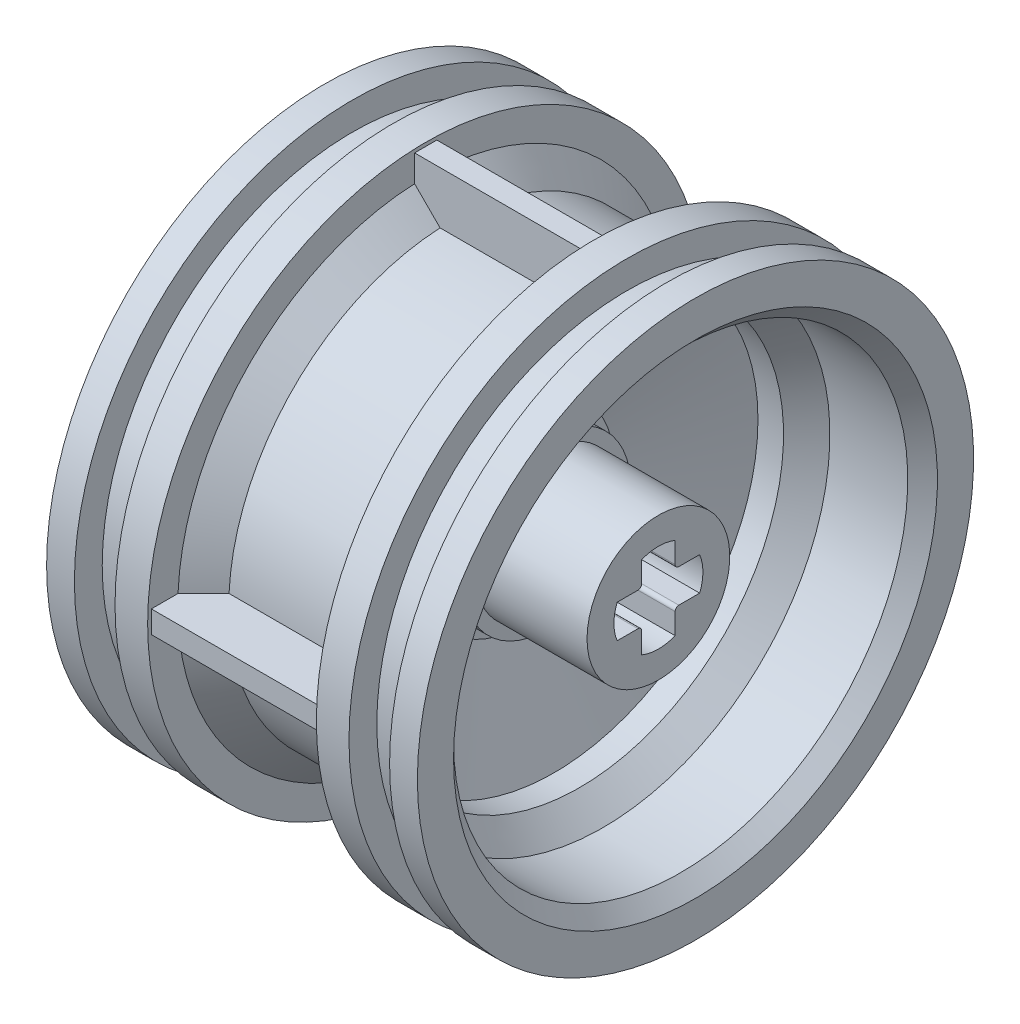
from build123d import *

# Parameters (mm, degrees)
CUT_EXTRUDE2_REACH = 29.821
RIB1_REACH         = 25.452
SKETCH7_WALL_W     = 58.004157598
SKETCH7_WALL_H     = 1.2
CIRPATTERN1_COUNT  = 4
CHAMFER1_SIZE      = 0.8


with BuildPart() as part:
    # Sketch1 → Revolve1 (revolve)
    with BuildSketch(Plane.XY, mode=Mode.PRIVATE) as revolve1_sk:
        Polygon((10, 12.25), (10, 15), (8.5, 15), (8.5, 13.5), (6.31, 13.5), (6.31, 15), (4.55, 15), (4.55, 13.375), (3.175, 12), (-3.175, 12), (-4.55, 13.375), (-4.55, 15), (-6.31, 15), (-6.31, 13.5), (-8.5, 13.5), (-8.5, 15), (-10, 15), (-10, 12.25), (-5, 12.25), (-3.75, 11), (3.75, 11), (5, 12.25), align=None)
    revolve(revolve1_sk.sketch.rotate(Axis((0, 0, 0), (1, 0, 0)), 90), axis=Axis((0, 0, 0), (1, 0, 0)))

    # Sketch2 → Revolve3 (revolve)
    with BuildSketch(Plane.XY, mode=Mode.PRIVATE) as revolve3_sk:
        Polygon((1, 11), (2.37, 11), (0.5, 5.1), (0.5, 4.5), (2, 4.5), (2, 3.85), (8, 3.85), (8, 0), (0.6, 0), (0.6, 3.804964539), (-3.4, 3.804964539), (-3.4, 5.8), (-0.648135593, 5.8), align=None)
    revolve(revolve3_sk.sketch.rotate(Axis((0, 0, 0), (1, 0, 0)), 90), axis=Axis((0, 0, 0), (1, 0, 0)))

    # Sketch5 → Cut-Extrude2 (cut, up to next)
    with BuildSketch(Plane(origin=(8, 0, 0), x_dir=(0, 0, -1), z_dir=(1, 0, 0)), mode=Mode.PRIVATE) as cut_extrude2_sk1:
        with BuildLine():
            Line((0.9, 1.1), (0.9, 2.224859546))
            ThreePointArc((0.9, 2.224859546), (0, 2.4), (-0.9, 2.224859546))
            Line((-0.9, 2.224859546), (-0.9, 1.1))
            ThreePointArc((-0.9, 1.1), (-0.958578644, 0.958578644), (-1.1, 0.9))
            Line((-1.1, 0.9), (-2.224859546, 0.9))
            ThreePointArc((-2.224859546, 0.9), (-2.4, 0), (-2.224859546, -0.9))
            Line((-2.224859546, -0.9), (-1.1, -0.9))
            ThreePointArc((-1.1, -0.9), (-0.958578644, -0.958578644), (-0.9, -1.1))
            Line((-0.9, -1.1), (-0.9, -2.224859546))
            ThreePointArc((-0.9, -2.224859546), (0, -2.4), (0.9, -2.224859546))
            Line((0.9, -2.224859546), (0.9, -1.1))
            ThreePointArc((0.9, -1.1), (0.958578644, -0.958578644), (1.1, -0.9))
            Line((1.1, -0.9), (2.224859546, -0.9))
            ThreePointArc((2.224859546, -0.9), (2.4, 0), (2.224859546, 0.9))
            Line((2.224859546, 0.9), (1.1, 0.9))
            ThreePointArc((1.1, 0.9), (0.958578644, 0.958578644), (0.9, 1.1))
        make_face()
    cut_extrude2_tool1 = extrude(cut_extrude2_sk1.sketch, amount=-CUT_EXTRUDE2_REACH, mode=Mode.PRIVATE) & part.part
    add(cut_extrude2_tool1.solids().sort_by_distance((8, 0, 0))[0], mode=Mode.SUBTRACT)

    # Sketch7 wall → Rib1 (add, up to next)
    with BuildSketch(Plane(origin=(0, 14.8, 0), x_dir=(-1, 0, 0), z_dir=(0, -1, 0)), mode=Mode.PRIVATE) as rib1_sk1:
        Rectangle(SKETCH7_WALL_W, SKETCH7_WALL_H)
    rib1_tool1 = extrude(rib1_sk1.sketch, amount=RIB1_REACH, mode=Mode.PRIVATE) - part.part
    rib1 = rib1_tool1.solids().sort_by_distance((0, 14.8, 0))[0]
    add(rib1)

    # CirPattern1: Rib1 ×4 about axis
    cirpattern1_axis = Axis((0, 0, 0), (1, 0, 0))
    for i in range(1, CIRPATTERN1_COUNT):
        add(rib1.rotate(cirpattern1_axis, i * 360 / CIRPATTERN1_COUNT))

    # Chamfer1
    chamfer1_edges = [part.edges().sort_by_distance(p)[0] for p in [
        (10, 0, -12.25),
        (-10, 0, -12.25),
    ]]
    chamfer(chamfer1_edges, length=CHAMFER1_SIZE)


solid = part.part
